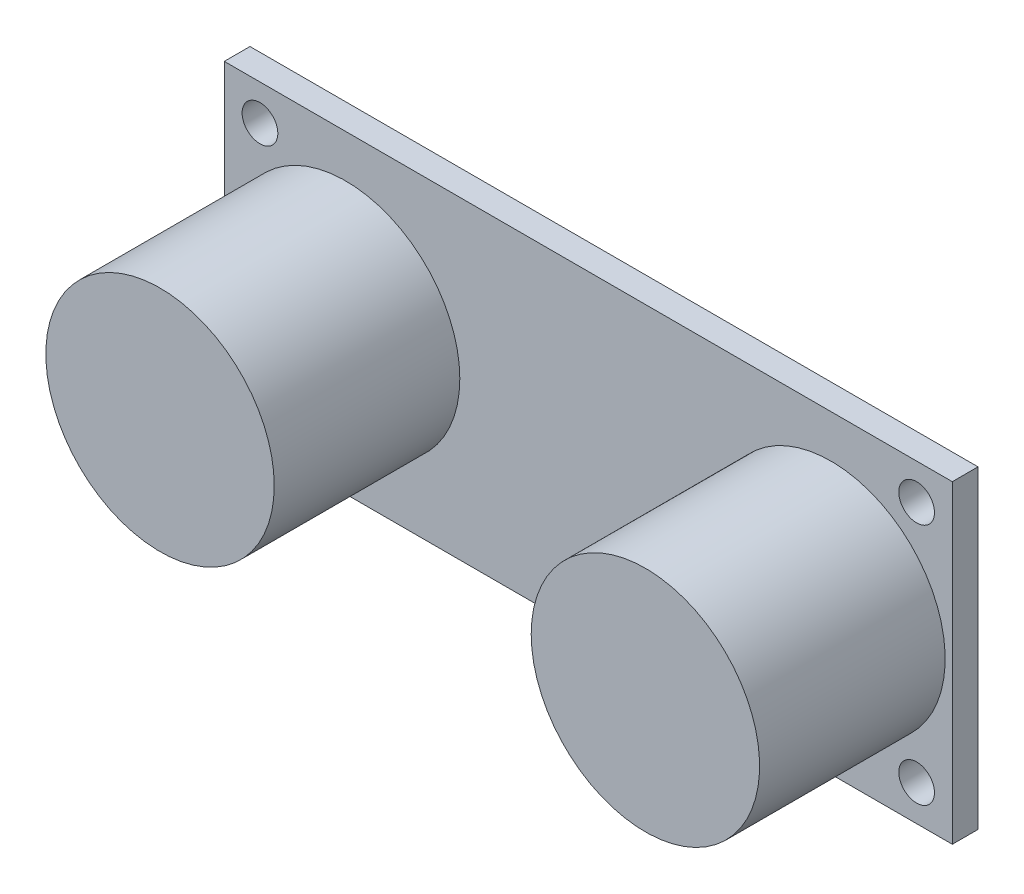
from build123d import *

# Parameters (mm, degrees)
SKETCH1_W           = 51
SKETCH1_H           = 22
SKETCH1_R           = 1.25
BOSS_EXTRUDE1_DEPTH = 1.8
SKETCH2_R           = 8
BOSS_EXTRUDE2_DEPTH = 13


with BuildPart() as part:
    # Sketch1 → Boss-Extrude1 (new body)
    with BuildSketch(Plane.XY):
        Rectangle(SKETCH1_W, SKETCH1_H)
        with Locations((-23, -8.5)):
            Circle(SKETCH1_R, mode=Mode.SUBTRACT)
        with Locations((-23, 8.5)):
            Circle(SKETCH1_R, mode=Mode.SUBTRACT)
        with Locations((23, 8.5)):
            Circle(SKETCH1_R, mode=Mode.SUBTRACT)
        with Locations((23, -8.5)):
            Circle(SKETCH1_R, mode=Mode.SUBTRACT)
    extrude(amount=BOSS_EXTRUDE1_DEPTH)

    # Sketch2 → Boss-Extrude2 (add)
    with BuildSketch(Plane.XY.offset(1.8)):
        with Locations((-17, 0)):
            Circle(SKETCH2_R)
        with Locations((17, 0)):
            Circle(SKETCH2_R)
    extrude(amount=BOSS_EXTRUDE2_DEPTH)


solid = part.part
